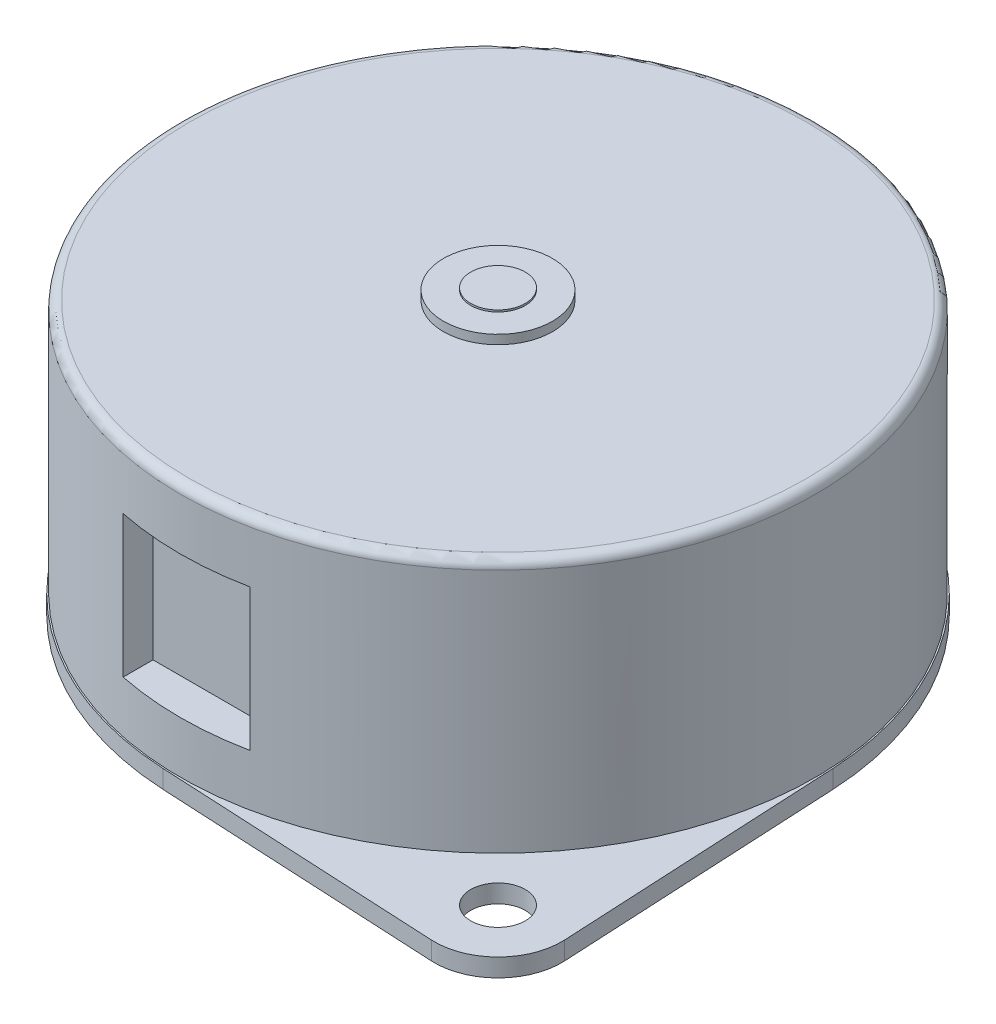
from build123d import *

# Parameters (mm, degrees)
SKETCH1_R           = 17.5
BOSS_EXTRUDE1_DEPTH = 14
SKETCH2_R           = 1.5
BOSS_EXTRUDE2_DEPTH = 1
SKETCH3_R           = 5
BOSS_EXTRUDE3_DEPTH = 1.5
SKETCH4_R           = 1.5
BOSS_EXTRUDE4_DEPTH = 11
SKETCH5_R           = 3
BOSS_EXTRUDE5_DEPTH = 0.5
SKETCH6_R           = 1.5
BOSS_EXTRUDE6_DEPTH = 0.1
FILLET1_R           = 0.5
SKETCH7_W           = 7
SKETCH7_H           = 7.8
CUT_EXTRUDE3_DEPTH  = 2


with BuildPart() as part:
    # Sketch1 → Boss-Extrude1 (new body)
    with BuildSketch(Plane(origin=(0, 0, 0), x_dir=(1, 0, 0), z_dir=(0, 1, 0))):
        Circle(SKETCH1_R)
    extrude(amount=BOSS_EXTRUDE1_DEPTH)

    # Sketch2 → Boss-Extrude2 (add)
    with BuildSketch(Plane.XZ):
        with BuildLine():
            Line((14.671631406, 18.344732976), (-0.891940662, 17.553925067))
            ThreePointArc((-0.891940662, 17.553925067), (-12.428512449, 12.428512449), (-17.553925067, 0.891940662))
            Line((-17.553925067, 0.891940662), (-18.344732976, -14.671631406))
            ThreePointArc((-18.344732976, -14.671631406), (-17.324116139, -17.324116139), (-14.671631406, -18.344732976))
            Line((-14.671631406, -18.344732976), (0.891940662, -17.553925067))
            ThreePointArc((0.891940662, -17.553925067), (12.428512449, -12.428512449), (17.553925067, -0.891940662))
            Line((17.553925067, -0.891940662), (18.344732976, 14.671631406))
            ThreePointArc((18.344732976, 14.671631406), (17.324116139, 17.324116139), (14.671631406, 18.344732976))
        make_face()
        with Locations((14.849242405, 14.849242405)):
            Circle(SKETCH2_R, mode=Mode.SUBTRACT)
        with Locations((-14.849242405, -14.849242405)):
            Circle(SKETCH2_R, mode=Mode.SUBTRACT)
    extrude(amount=BOSS_EXTRUDE2_DEPTH)

    # Sketch3 → Boss-Extrude3 (add)
    with BuildSketch(Plane.XZ.offset(1)):
        Circle(SKETCH3_R)
    extrude(amount=BOSS_EXTRUDE3_DEPTH)

    # Sketch4 → Boss-Extrude4 (add)
    with BuildSketch(Plane.XZ.offset(2.5)):
        Circle(SKETCH4_R)
    extrude(amount=BOSS_EXTRUDE4_DEPTH)

    # Sketch5 → Boss-Extrude5 (add)
    with BuildSketch(Plane(origin=(0, 14, 0), x_dir=(1, 0, 0), z_dir=(0, 1, 0))):
        Circle(SKETCH5_R)
    extrude(amount=BOSS_EXTRUDE5_DEPTH)

    # Sketch6 → Boss-Extrude6 (add)
    with BuildSketch(Plane(origin=(0, 14.5, 0), x_dir=(1, 0, 0), z_dir=(0, 1, 0))):
        Circle(SKETCH6_R)
    extrude(amount=BOSS_EXTRUDE6_DEPTH)

    # Fillet1
    fillet1_edges = [part.edges().sort_by_distance(p)[0] for p in [
        (-17.5, 14, 0),
    ]]
    fillet(fillet1_edges, radius=FILLET1_R)

    # Sketch7 → Cut-Extrude3 (cut)
    with BuildSketch(Plane.XY.offset(17.5)):
        with Locations((0, 6.75)):
            Rectangle(SKETCH7_W, SKETCH7_H)
    extrude(amount=-CUT_EXTRUDE3_DEPTH, mode=Mode.SUBTRACT)


solid = part.part
